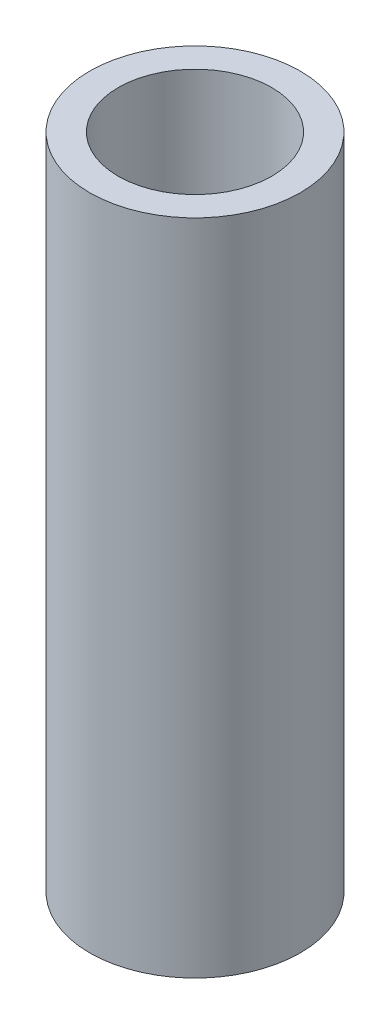
from build123d import *

# Parameters (mm, degrees)
SKETCH2_R           = 2.4
BOSS_EXTRUDE1_DEPTH = 15
SKETCH3_R           = 1.75
CUT_EXTRUDE1_DEPTH  = 15


with BuildPart() as part:
    # Sketch2 → Boss-Extrude1 (new body)
    with BuildSketch(Plane(origin=(0, 0, 0), x_dir=(1, 0, 0), z_dir=(0, 1, 0))):
        Circle(SKETCH2_R)
    extrude(amount=BOSS_EXTRUDE1_DEPTH)

    # Sketch3 → Cut-Extrude1 (cut)
    with BuildSketch(Plane(origin=(0, 15, 0), x_dir=(1, 0, 0), z_dir=(0, 1, 0))):
        Circle(SKETCH3_R)
    extrude(amount=-CUT_EXTRUDE1_DEPTH, mode=Mode.SUBTRACT)


solid = part.part
